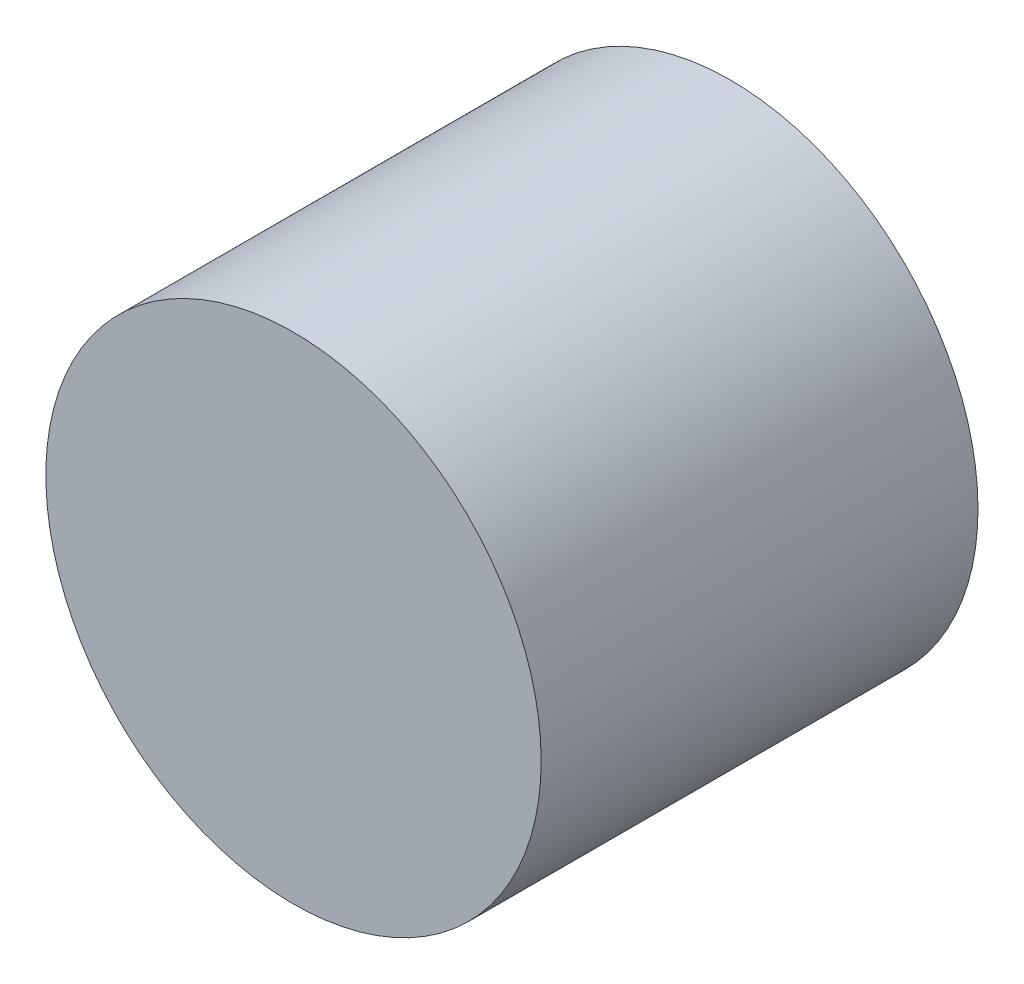
from build123d import *

# Parameters (mm, degrees)
SKETCH1_R           = 7.2
BOSS_EXTRUDE1_DEPTH = 12.7


with BuildPart() as part:
    # Sketch1 → Boss-Extrude1 (new body)
    with BuildSketch(Plane.XY):
        Circle(SKETCH1_R)
    extrude(amount=BOSS_EXTRUDE1_DEPTH)


solid = part.part
